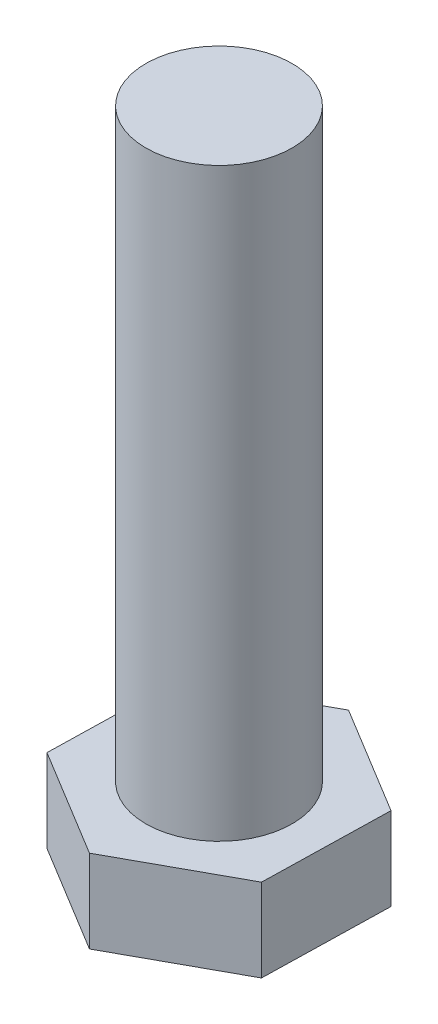
from build123d import *

# Parameters (mm, degrees)
EXTRUDE_1_DEPTH = 12.5
SKETCH_2_R      = 10
EXTRUDE_2_DEPTH = 80
CHAMFER_1_SIZE  = 2
CHAMFER_1_SIZE2 = 1.154700538


with BuildPart() as part:
    # Эскиз1 → Бобышка-Вытянуть1 (new body)
    with BuildSketch(Plane(origin=(0, 0, 0), x_dir=(1, 0, 0), z_dir=(0, 1, 0))):
        Polygon((14.801582536, -8.995173953), (15.190840422, 8.320959516), (0.389257887, 17.316133468), (-14.801582536, 8.995173953), (-15.190840422, -8.320959516), (-0.389257887, -17.316133468), align=None)
    extrude(amount=EXTRUDE_1_DEPTH)

    # Эскиз2 → Бобышка-Вытянуть2 (add)
    with BuildSketch(Plane(origin=(0, 12.5, 0), x_dir=(1, 0, 0), z_dir=(0, 1, 0))):
        Circle(SKETCH_2_R)
    extrude(amount=EXTRUDE_2_DEPTH)

    # Фаска1
    chamfer_1_edges = [part.edges().sort_by_distance(p)[0] for p in [
        (-7.790049154, 0, 12.818546492),
        (-14.996211479, 0, -0.337107218),
        (-7.206162325, 0, -13.155653711),
        (7.790049154, 0, -12.818546492),
        (14.996211479, 0, 0.337107218),
        (7.206162325, 0, 13.155653711),
    ]]
    chamfer_1_side = [part.faces().sort_by_distance(p)[0] for p in [
        (0, 0, 0),
    ]]
    chamfer(chamfer_1_edges, length=CHAMFER_1_SIZE, length2=CHAMFER_1_SIZE2, reference=chamfer_1_side[0])


solid = part.part
